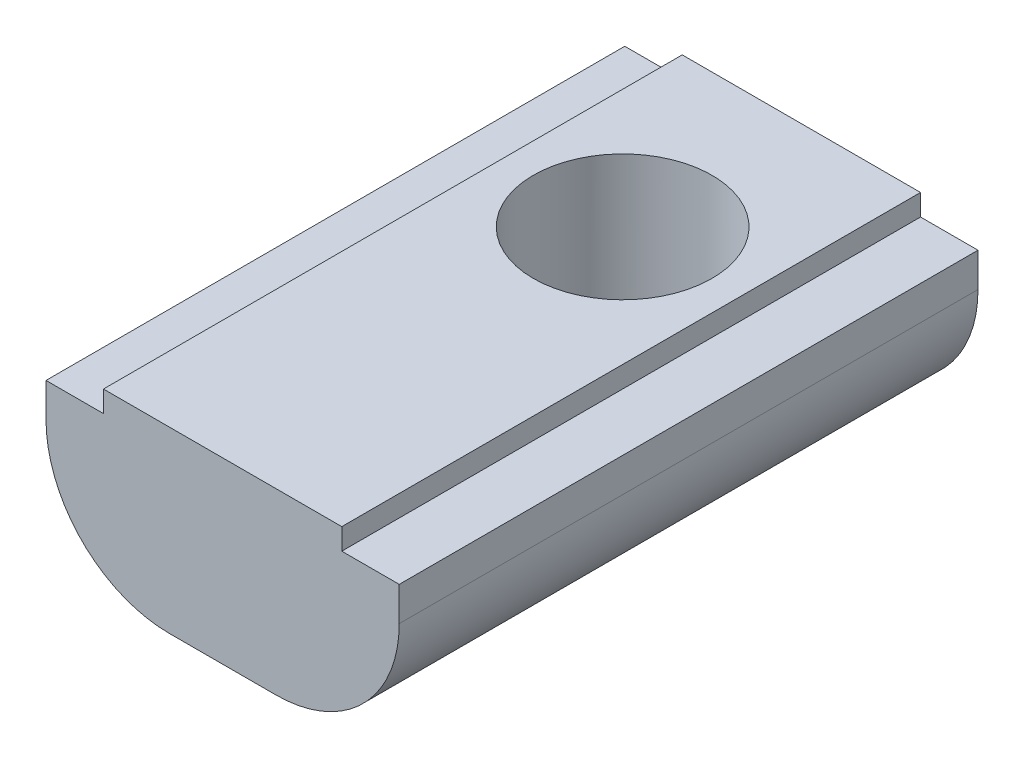
from build123d import *

# Parameters (mm, degrees)
BOSS_EXTRUDE1_DEPTH   = 13.6
M5X0_8_TAPPED_HOLE1_D = 4.2


with BuildPart() as part:
    # Sketch1 → Boss-Extrude1 (new body)
    with BuildSketch(Plane.XY):
        with BuildLine():
            Line((2.8, 0), (-2.8, 0))
            Line((-2.8, 0), (-2.8, -0.5))
            Line((-2.8, -0.5), (-4.15, -0.5))
            Line((-4.15, -0.5), (-4.15, -1.3))
            ThreePointArc((-4.15, -1.3), (-3.300609665, -3.350609665), (-1.25, -4.2))
            Line((-1.25, -4.2), (1.25, -4.2))
            ThreePointArc((1.25, -4.2), (3.300609665, -3.350609665), (4.15, -1.3))
            Line((4.15, -1.3), (4.15, -0.5))
            Line((4.15, -0.5), (2.8, -0.5))
            Line((2.8, -0.5), (2.8, 0))
        make_face()
    extrude(amount=BOSS_EXTRUDE1_DEPTH)

    # M5x0.8 Tapped Hole1 (through all)
    with Locations(Plane(origin=(0, 0, 0), x_dir=(1, 0, 0), z_dir=(0, 1, 0))):
        with Locations((0, -4.2)):
            Hole(M5X0_8_TAPPED_HOLE1_D / 2)


solid = part.part
